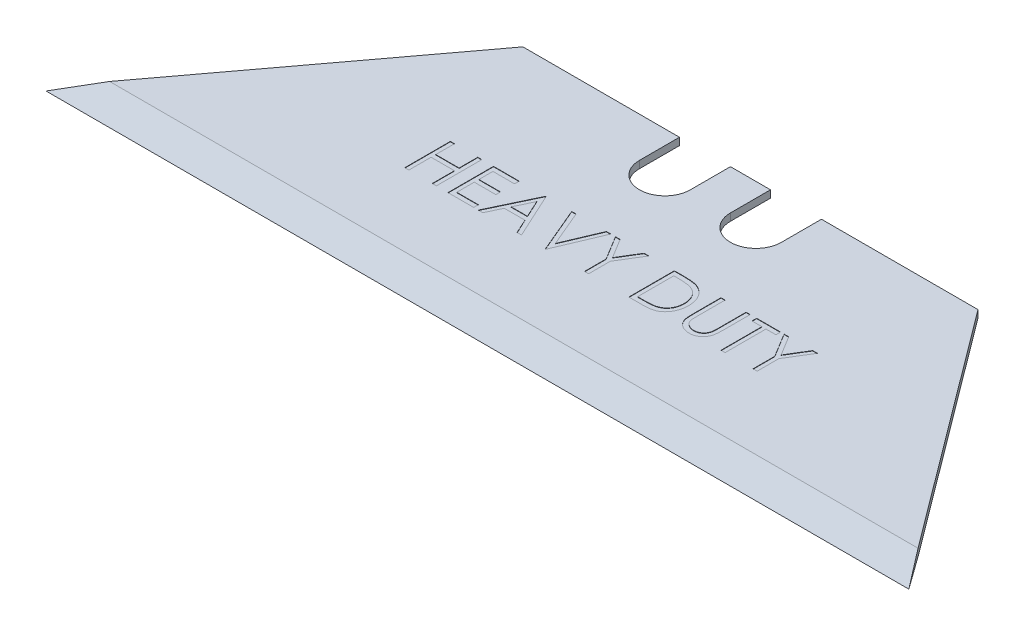
from build123d import *

# Parameters (mm, degrees)
BOSS_EXTRUDE1_DEPTH = 0.254
CUT_EXTRUDE1_DEPTH  = 1.508
CUT_EXTRUDE2_DEPTH  = 31.099
CUT_EXTRUDE3_DEPTH  = 0.0254


with BuildPart() as part:
    # Sketch1 → Boss-Extrude1 (new body, symmetric)
    with BuildSketch(Plane(origin=(0, 0, 0), x_dir=(1, 0, 0), z_dir=(0, 1, 0))):
        Polygon((-15.875, 6.578038674), (-30.099, -12.471961326), (30.099, -12.471961326), (15.875, 6.578038674), align=None)
    extrude(amount=BOSS_EXTRUDE1_DEPTH, both=True)

    # Sketch2 → Cut-Extrude1 (cut, through all)
    with BuildSketch(Plane(origin=(0, 0.254, 0), x_dir=(1, 0, 0), z_dir=(0, 1, 0))):
        with BuildLine():
            Line((-4.953, 3.784038674), (-4.953, 6.578038674))
            Line((-4.953, 6.578038674), (-1.397, 6.578038674))
            Line((-1.397, 6.578038674), (-1.397, 3.784038674))
            ThreePointArc((-1.397, 3.784038674), (-3.175, 2.006038674), (-4.953, 3.784038674))
        make_face()
        with BuildLine():
            Line((1.397, 3.784038674), (1.397, 6.578038674))
            Line((1.397, 6.578038674), (4.953, 6.578038674))
            Line((4.953, 6.578038674), (4.953, 3.784038674))
            ThreePointArc((4.953, 3.784038674), (3.175, 2.006038674), (1.397, 3.784038674))
        make_face()
    extrude(amount=-CUT_EXTRUDE1_DEPTH, mode=Mode.SUBTRACT)

    # Sketch3 → Cut-Extrude2 (cut, symmetric)
    with BuildSketch(Plane(origin=(0, 0, 0), x_dir=(0, 0, -1), z_dir=(1, 0, 0))):
        Polygon((-12.471961326, 0), (-9.931961326, 0.254), (-12.471961326, 0.254), align=None)
    cut_extrude2 = extrude(amount=CUT_EXTRUDE2_DEPTH, both=True, mode=Mode.SUBTRACT)

    # Mirror1: Cut-Extrude2 across plane
    add(cut_extrude2.mirror(Plane.ZX), mode=Mode.SUBTRACT)

    # Sketch4 → Cut-Extrude3 (cut)
    with BuildSketch(Plane(origin=(0, 0.254, 0), x_dir=(1, 0, 0), z_dir=(0, 1, 0))):
        Polygon((-12.694002001, -1.667291369), (-12.409066104, -1.667291369), (-12.409066104, -2.969855472), (-10.780860975, -2.969855472), (-10.780860975, -1.667291369), (-10.495925078, -1.667291369), (-10.495925078, -4.842291369), (-10.780860975, -4.842291369), (-10.780860975, -3.295496498), (-12.409066104, -3.295496498), (-12.409066104, -4.842291369), (-12.694002001, -4.842291369), align=None)
        Polygon((-9.681822514, -1.667291369), (-7.890796873, -1.667291369), (-7.890796873, -1.992932395), (-9.396886616, -1.992932395), (-9.396886616, -2.969855472), (-7.890796873, -2.969855472), (-7.890796873, -3.295496498), (-9.396886616, -3.295496498), (-9.396886616, -4.516650344), (-7.890796873, -4.516650344), (-7.890796873, -4.842291369), (-9.681822514, -4.842291369), align=None)
        Polygon((-6.018360975, -1.667291369), (-4.55297636, -4.842291369), (-4.862716945, -4.842291369), (-5.332097955, -3.824663164), (-6.771405847, -3.824663164), (-7.254143227, -4.842291369), (-7.565155847, -4.842291369), (-6.059066104, -1.667291369), align=None)
        Polygon((-6.041893628, -2.286136522), (-6.616853564, -3.499022139), (-5.482198115, -3.499022139), align=None, mode=Mode.SUBTRACT)
        Polygon((-4.227335334, -1.667291369), (-3.922046873, -1.667291369), (-2.86371354, -4.169384719), (-1.805380206, -1.667291369), (-1.500091745, -1.667291369), (-2.843360975, -4.842291369), (-2.884066104, -4.842291369), align=None)
        Polygon((-1.174450719, -1.667291369), (-0.848173676, -1.667291369), (-0.013718548, -3.031549182), (0.819464545, -1.667291369), (1.145741589, -1.667291369), (0.128113384, -3.333021538), (0.128113384, -4.842291369), (-0.156822514, -4.842291369), (-0.156822514, -3.333021538), align=None)
        with BuildLine():
            Line((2.93676723, -4.842291369), (2.93676723, -1.667291369))
            Line((2.93676723, -1.667291369), (3.577872999, -1.667291369))
            add(Edge.make_bspline(
                [(3.577872999, -1.667291369), (3.633634153, -1.667692844), (3.741364411, -1.66846849), (3.897041417, -1.673386466), (4.041080973, -1.682086389), (4.173009352, -1.694758744), (4.293188737, -1.710318996), (4.401282618, -1.729822935), (4.497849919, -1.752853632), (4.557240054, -1.772489148), (4.585324922, -1.781774543)],
                knots=[0, 0, 0, 0, 0.000167284, 0.000323191, 0.000467206, 0.000600108, 0.000720732, 0.000830638, 0.000929518, 0.001018226, 0.001018226, 0.001018226, 0.001018226], degree=3))
            add(Edge.make_bspline(
                [(4.585324922, -1.781774543), (4.622059436, -1.795772397), (4.694695446, -1.823450681), (4.798116193, -1.875662469), (4.895475629, -1.934820068), (4.987295853, -2.001001458), (5.07147946, -2.076080545), (5.151315195, -2.156868044), (5.223537123, -2.246301753), (5.289675363, -2.342526921), (5.349306997, -2.444409997), (5.401140376, -2.551756845), (5.444187927, -2.664022312), (5.479923211, -2.780894197), (5.508086783, -2.902629482), (5.527301821, -3.029369918), (5.539975505, -3.160614611), (5.54124918, -3.249672875), (5.541895435, -3.29486048)],
                knots=[0, 0, 0, 0, 0.000117869, 0.000233066, 0.000346943, 0.000459403, 0.000572066, 0.000684957, 0.000799786, 0.0009164, 0.001034974, 0.001153596, 0.001273599, 0.001395318, 0.001519979, 0.001648073, 0.001779649, 0.001915175, 0.001915175, 0.001915175, 0.001915175], degree=3))
            add(Edge.make_bspline(
                [(5.541895435, -3.29486048), (5.541324871, -3.334104604), (5.540200517, -3.411439248), (5.530104637, -3.525413489), (5.515430404, -3.636006514), (5.492711739, -3.742691685), (5.465132316, -3.846403711), (5.429786265, -3.946037247), (5.389295493, -4.042506274), (5.342078817, -4.134506413), (5.290243418, -4.221667758), (5.234615837, -4.303832701), (5.175255406, -4.379828795), (5.111596082, -4.449886179), (5.044460511, -4.51389924), (4.973409154, -4.572402711), (4.898258672, -4.624251871), (4.819345659, -4.671484176), (4.734368028, -4.712686927), (4.641716206, -4.747548436), (4.540995066, -4.776437866), (4.432451834, -4.800541464), (4.315898965, -4.819661589), (4.191222188, -4.832476245), (4.058613061, -4.84114212), (3.967554728, -4.841900848), (3.920686501, -4.842291369)],
                knots=[0, 0, 0, 0, 0.000117706, 0.000231952, 0.000343037, 0.000452182, 0.00055895, 0.000664755, 0.000769064, 0.000872602, 0.000974698, 0.001073133, 0.001170083, 0.001263736, 0.001356857, 0.001448148, 0.00153954, 0.00163051, 0.001723812, 0.001822446, 0.001927109, 0.0020379, 0.002155845, 0.002281218, 0.002413768, 0.002554351, 0.002554351, 0.002554351, 0.002554351], degree=3))
            Line((3.920686501, -4.842291369), (2.93676723, -4.842291369))
        make_face()
        with BuildLine():
            Line((3.221703127, -4.516650344), (3.586141228, -4.516650344))
            add(Edge.make_bspline(
                [(3.586141228, -4.516650344), (3.638509107, -4.516425285), (3.739231717, -4.515992414), (3.884064329, -4.512194023), (4.016397782, -4.505987408), (4.136250865, -4.497301445), (4.243555909, -4.485809201), (4.338537167, -4.472995896), (4.420883295, -4.457032495), (4.470712141, -4.442562696), (4.493738384, -4.435876105)],
                knots=[0, 0, 0, 0, 0.000157102, 0.000302164, 0.000434608, 0.000554511, 0.000662606, 0.000758309, 0.000842005, 0.000913909, 0.000913909, 0.000913909, 0.000913909], degree=3))
            add(Edge.make_bspline(
                [(4.493738384, -4.435876105), (4.522720112, -4.425669334), (4.579991341, -4.405499581), (4.662433468, -4.368707989), (4.73932018, -4.325126968), (4.811991417, -4.276683477), (4.879416311, -4.221668889), (4.942393903, -4.161279492), (5.000797394, -4.095207947), (5.054023373, -4.023536257), (5.101655906, -3.946710514), (5.142904807, -3.865486001), (5.179055839, -3.78075268), (5.207429991, -3.691209372), (5.229669128, -3.597656583), (5.245421381, -3.500087732), (5.255231881, -3.398521041), (5.256376194, -3.329440185), (5.256959537, -3.294224462)],
                knots=[0, 0, 0, 0, 9.2159e-05, 0.000182117, 0.000270395, 0.000357008, 0.000443824, 0.00053109, 0.000618505, 0.000708057, 0.0007986, 0.000889339, 0.000981122, 0.001074651, 0.001170759, 0.00126936, 0.001370936, 0.001476563, 0.001476563, 0.001476563, 0.001476563], degree=3))
            add(Edge.make_bspline(
                [(5.256959537, -3.294224462), (5.256493912, -3.257091948), (5.255579188, -3.184144795), (5.244081778, -3.077110379), (5.227280081, -2.974167217), (5.202983452, -2.875308426), (5.172021869, -2.780341135), (5.133382444, -2.689790579), (5.089234868, -2.602700448), (5.036708269, -2.521080845), (4.979181267, -2.443889239), (4.915338476, -2.373172994), (4.846194198, -2.308771021), (4.772502585, -2.249680359), (4.692186788, -2.19827831), (4.607138797, -2.15229825), (4.516110938, -2.113276691), (4.45278085, -2.092522294), (4.420596356, -2.081974863)],
                knots=[0, 0, 0, 0, 0.000111349, 0.000218745, 0.000322574, 0.000424076, 0.000523836, 0.000621881, 0.000719165, 0.000816384, 0.000912677, 0.0010077, 0.001101747, 0.001195912, 0.001290646, 0.001387396, 0.001485691, 0.001587265, 0.001587265, 0.001587265, 0.001587265], degree=3))
            add(Edge.make_bspline(
                [(4.420596356, -2.081974863), (4.393970674, -2.074612103), (4.337357167, -2.058956857), (4.244974224, -2.041879554), (4.14100191, -2.026816902), (4.02497861, -2.014064252), (3.897036579, -2.00491361), (3.757077419, -1.998045346), (3.605040635, -1.993412901), (3.499646479, -1.993096574), (3.444945315, -1.992932395)],
                knots=[0, 0, 0, 0, 8.2841e-05, 0.000176143, 0.000281561, 0.000398013, 0.000526208, 0.000666307, 0.00081838, 0.000982477, 0.000982477, 0.000982477, 0.000982477], degree=3))
            Line((3.444945315, -1.992932395), (3.221703127, -1.992932395))
            Line((3.221703127, -1.992932395), (3.221703127, -4.516650344))
        make_face(mode=Mode.SUBTRACT)
        with BuildLine():
            Line((6.193177486, -1.667291369), (6.478113384, -1.667291369))
            Line((6.478113384, -1.667291369), (6.478113384, -3.569620095))
            add(Edge.make_bspline(
                [(6.478113384, -3.569620095), (6.47807098, -3.596544763), (6.477990512, -3.647638959), (6.478528007, -3.72036306), (6.480033291, -3.785017363), (6.480982307, -3.841851085), (6.483093531, -3.890603434), (6.484815331, -3.931538538), (6.487029265, -3.964462564), (6.489690021, -3.98367669), (6.490833736, -3.991935801)],
                knots=[0, 0, 0, 0, 8.0774e-05, 0.000153283, 0.000218169, 0.000274789, 0.0003238, 0.00036455, 0.00039772, 0.000422728, 0.000422728, 0.000422728, 0.000422728], degree=3))
            add(Edge.make_bspline(
                [(6.490833736, -3.991935801), (6.495530431, -4.021732507), (6.504659178, -4.079646983), (6.527924107, -4.162113782), (6.560415697, -4.236437319), (6.5989176, -4.304936847), (6.649656469, -4.365705767), (6.710438247, -4.421687052), (6.78407808, -4.470647189), (6.865957344, -4.515415425), (6.954208952, -4.551397321), (7.044389173, -4.578605587), (7.135142446, -4.595187161), (7.195899396, -4.597107164), (7.226070114, -4.5980606)],
                knots=[0, 0, 0, 0, 9.0451e-05, 0.000175805, 0.000256145, 0.000333379, 0.000410662, 0.000492593, 0.000580446, 0.000675215, 0.000772184, 0.000865756, 0.00095746, 0.001047918, 0.001047918, 0.001047918, 0.001047918], degree=3))
            add(Edge.make_bspline(
                [(7.226070114, -4.5980606), (7.251972436, -4.597086465), (7.303627474, -4.59514382), (7.380377594, -4.583113807), (7.455126263, -4.56143258), (7.528242595, -4.533456513), (7.59677813, -4.496492627), (7.66077111, -4.453792651), (7.717888393, -4.403708499), (7.770011005, -4.348281758), (7.81539984, -4.285743511), (7.854743661, -4.217455486), (7.886970755, -4.142390007), (7.902885238, -4.089635638), (7.9110611, -4.062533757)],
                knots=[0, 0, 0, 0, 7.7722e-05, 0.000154995, 0.000232312, 0.000310854, 0.000389384, 0.000465414, 0.000541161, 0.000616765, 0.000693219, 0.000772423, 0.000852763, 0.000937642, 0.000937642, 0.000937642, 0.000937642], degree=3))
            add(Edge.make_bspline(
                [(7.9110611, -4.062533757), (7.913782642, -4.051331836), (7.919847335, -4.026369442), (7.925514297, -3.984167985), (7.931416645, -3.934375491), (7.935512005, -3.876634204), (7.939504541, -3.811137607), (7.941893114, -3.737544502), (7.942997137, -3.656122116), (7.94332614, -3.599301262), (7.943497999, -3.569620095)],
                knots=[0, 0, 0, 0, 3.4562e-05, 7.7018e-05, 0.000127589, 0.000185003, 0.000250624, 0.000324446, 0.000405866, 0.000494911, 0.000494911, 0.000494911, 0.000494911], degree=3))
            Line((7.943497999, -3.569620095), (7.943497999, -1.667291369))
            Line((7.943497999, -1.667291369), (8.228433896, -1.667291369))
            Line((8.228433896, -1.667291369), (8.228433896, -3.584884519))
            add(Edge.make_bspline(
                [(8.228433896, -3.584884519), (8.228203373, -3.619445191), (8.227753492, -3.686892444), (8.223852255, -3.785726891), (8.217631977, -3.87948281), (8.208843497, -3.968172803), (8.197198501, -4.051479505), (8.184248837, -4.130133116), (8.167757403, -4.203569045), (8.148495675, -4.272359881), (8.126476099, -4.337842454), (8.097954486, -4.399989554), (8.065819404, -4.460690474), (8.027706112, -4.519027116), (7.984878643, -4.575257775), (7.936390333, -4.629041436), (7.883844844, -4.68123757), (7.826368672, -4.73050728), (7.764909267, -4.775690866), (7.699649448, -4.815421701), (7.631090521, -4.849007411), (7.5594107, -4.876653428), (7.484579394, -4.897440243), (7.406594718, -4.912929849), (7.325279164, -4.921731219), (7.269975512, -4.923039255), (7.241970555, -4.923701626)],
                knots=[0, 0, 0, 0, 0.000103679, 0.000202335, 0.00029668, 0.000385534, 0.000469635, 0.000548998, 0.000624606, 0.000695284, 0.00076327, 0.000831594, 0.000900171, 0.000969149, 0.001040386, 0.001112008, 0.001186215, 0.001262445, 0.001338899, 0.001414817, 0.001491333, 0.001567636, 0.001644954, 0.001724035, 0.001805931, 0.001889945, 0.001889945, 0.001889945, 0.001889945], degree=3))
            add(Edge.make_bspline(
                [(7.241970555, -4.923701626), (7.211427869, -4.922989732), (7.151503229, -4.921592998), (7.063203696, -4.913589503), (6.978554389, -4.898514245), (6.896661272, -4.879319154), (6.818639279, -4.852845335), (6.743443083, -4.821913464), (6.672360565, -4.783924807), (6.604238555, -4.741657943), (6.540897526, -4.694101307), (6.482752025, -4.642267006), (6.429706057, -4.586985378), (6.382653739, -4.527657904), (6.340815508, -4.464745998), (6.304774529, -4.398071688), (6.273828943, -4.327660787), (6.257857272, -4.278717526), (6.249783055, -4.253975063)],
                knots=[0, 0, 0, 0, 9.1642e-05, 0.000179801, 0.000265647, 0.00034941, 0.000431872, 0.000512549, 0.000593062, 0.000673357, 0.000752859, 0.000830344, 0.000906819, 0.000982409, 0.001057203, 0.00113319, 0.001209523, 0.001287564, 0.001287564, 0.001287564, 0.001287564], degree=3))
            add(Edge.make_bspline(
                [(6.249783055, -4.253975063), (6.245086633, -4.237072657), (6.234899989, -4.20041096), (6.223991326, -4.139735359), (6.214820945, -4.069871827), (6.206198046, -3.99081558), (6.201109919, -3.902505344), (6.1966491, -3.804979399), (6.19314606, -3.69811982), (6.193166718, -3.623684652), (6.193177486, -3.584884519)],
                knots=[0, 0, 0, 0, 5.2605e-05, 0.000114102, 0.000184711, 0.00026401, 0.000352601, 0.000450014, 0.000556912, 0.000673305, 0.000673305, 0.000673305, 0.000673305], degree=3))
            Line((6.193177486, -3.584884519), (6.193177486, -1.667291369))
        make_face()
        Polygon((8.676190307, -1.992932395), (8.676190307, -1.667291369), (10.345100563, -1.667291369), (10.345100563, -1.992932395), (9.653113384, -1.992932395), (9.653113384, -4.842291369), (9.368177486, -4.842291369), (9.368177486, -1.992932395), align=None)
        Polygon((10.589331332, -1.667291369), (10.915608376, -1.667291369), (11.750063504, -3.031549182), (12.583246597, -1.667291369), (12.90952364, -1.667291369), (11.891895435, -3.333021538), (11.891895435, -4.842291369), (11.606959537, -4.842291369), (11.606959537, -3.333021538), align=None)
    extrude(amount=-CUT_EXTRUDE3_DEPTH, mode=Mode.SUBTRACT)


solid = part.part
